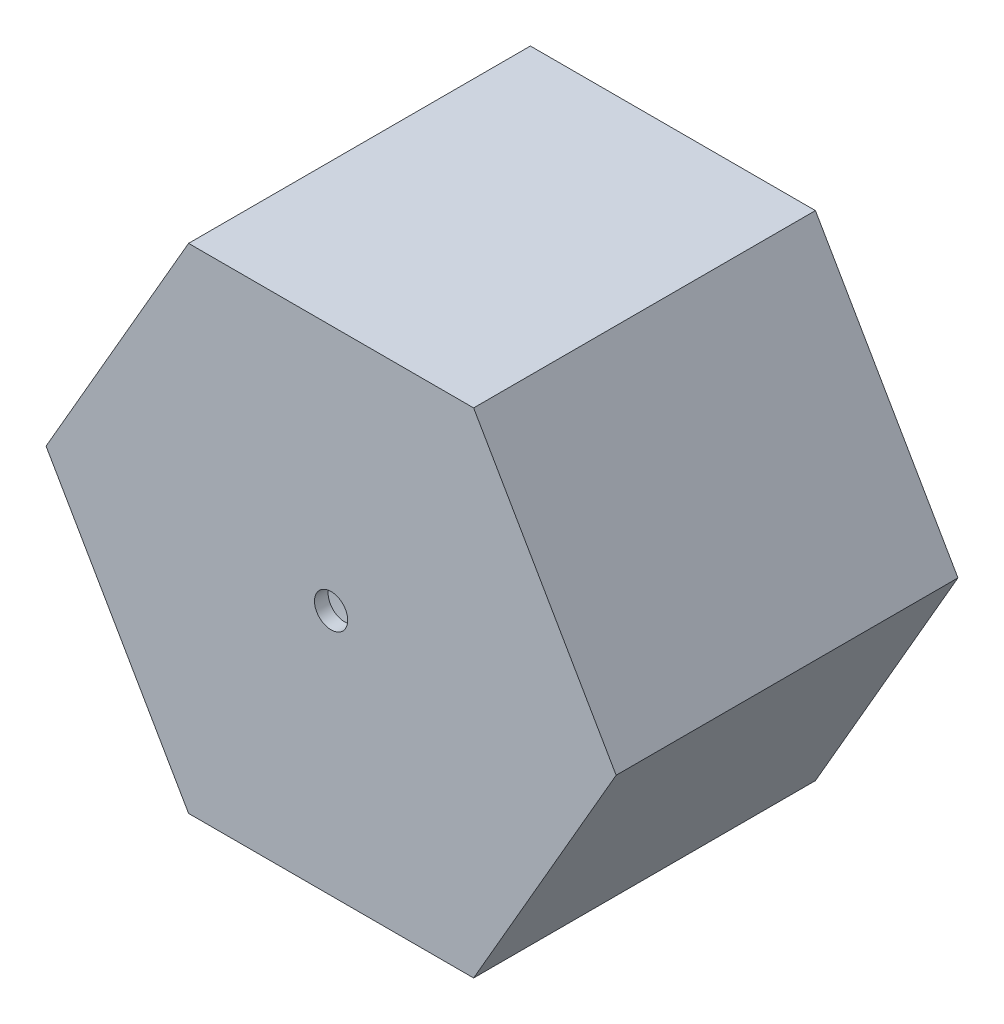
from build123d import *

# Parameters (mm, degrees)
AUFSATZ_LINEAR_AUSTRAGEN1_DEPTH      = 18
F_16_0_16_DURCHMESSER_BOHRUNG1_D     = 16
F_16_0_16_DURCHMESSER_BOHRUNG1_DEPTH = 13
F_16_0_16_DURCHMESSER_BOHRUNG1_TIP   = 4.806884952
F_1_75_1_75_DURCHMESSER_BOHRUNG1_D   = 1.75


with BuildPart() as part:
    # Skizze1 → Aufsatz-Linear austragen1 (new body)
    with BuildSketch(Plane.XY):
        Polygon((15.011106999, 0), (7.505553499, 13), (-7.505553499, 13), (-15.011106999, 0), (-7.505553499, -13), (7.505553499, -13), align=None)
    extrude(amount=AUFSATZ_LINEAR_AUSTRAGEN1_DEPTH)

    # Ø16.0 (16) Durchmesser Bohrung1
    with Locations(Plane(origin=(0, 0, 0), x_dir=(-1, 0, 0), z_dir=(0, 0, -1))):
        with Locations((0, 0)):
            Hole(F_16_0_16_DURCHMESSER_BOHRUNG1_D / 2, depth=F_16_0_16_DURCHMESSER_BOHRUNG1_DEPTH)
            with Locations((0, 0, -(F_16_0_16_DURCHMESSER_BOHRUNG1_DEPTH + F_16_0_16_DURCHMESSER_BOHRUNG1_TIP / 2))):  # 118° drill point
                Cone(0, F_16_0_16_DURCHMESSER_BOHRUNG1_D / 2, F_16_0_16_DURCHMESSER_BOHRUNG1_TIP, mode=Mode.SUBTRACT)

    # Ø1.75 (1.75) Durchmesser Bohrung1 (through all)
    with Locations(Plane.XY.offset(18)):
        with Locations((0, 0)):
            Hole(F_1_75_1_75_DURCHMESSER_BOHRUNG1_D / 2)


solid = part.part
